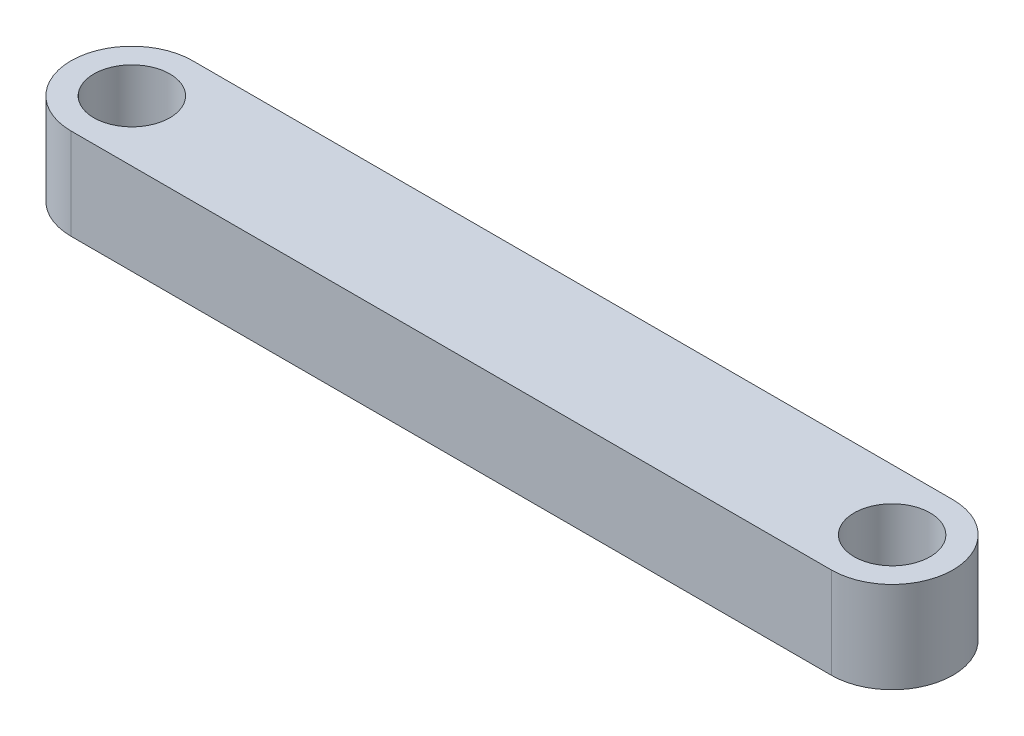
from build123d import *

# Parameters (mm, degrees)
SKETCH1_R           = 3.175
BOSS_EXTRUDE1_DEPTH = 7.62


with BuildPart() as part:
    # Sketch1 → Boss-Extrude1 (new body)
    with BuildSketch(Plane(origin=(0, 0, 0), x_dir=(1, 0, 0), z_dir=(0, 1, 0))):
        with BuildLine():
            Line((0, 5.08), (63.5, 5.08))
            ThreePointArc((63.5, 5.08), (68.58, 0), (63.5, -5.08))
            Line((63.5, -5.08), (0, -5.08))
            ThreePointArc((0, -5.08), (-5.08, 0), (0, 5.08))
        make_face()
        Circle(SKETCH1_R, mode=Mode.SUBTRACT)
        with Locations((63.5, 0)):
            Circle(SKETCH1_R, mode=Mode.SUBTRACT)
    extrude(amount=BOSS_EXTRUDE1_DEPTH)


solid = part.part
